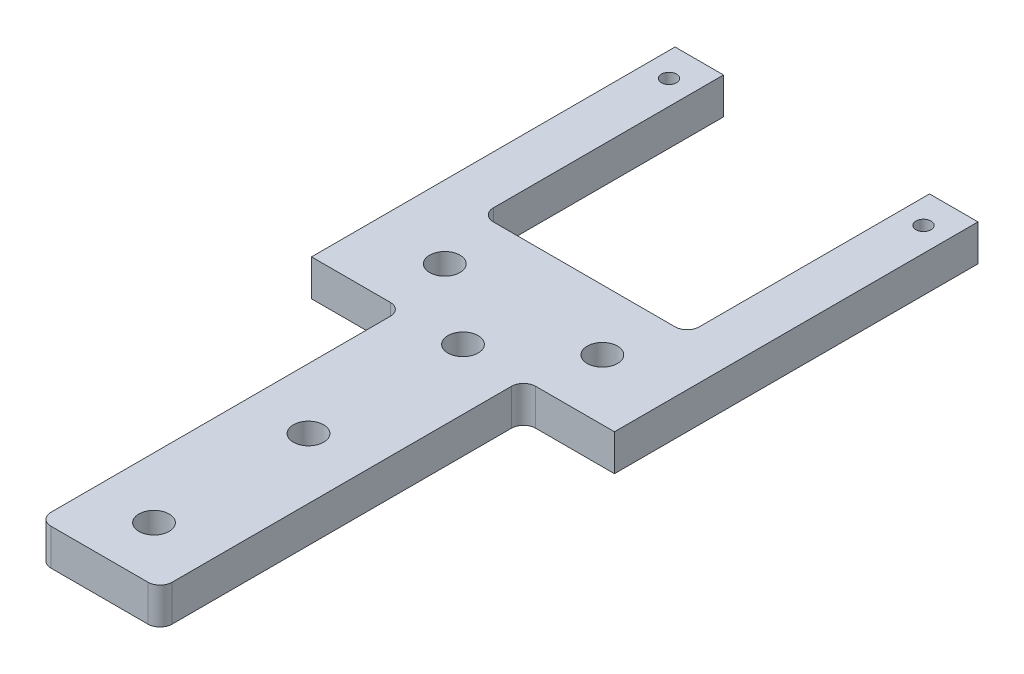
from build123d import *

# Parameters (mm, degrees)
SKETCH1_R           = 1.25
SKETCH1_R_2         = 0.625
BOSS_EXTRUDE1_DEPTH = 1.5
FILLET1_R           = 1


with BuildPart() as part:
    # Sketch1 → Boss-Extrude1 (new body, symmetric)
    with BuildSketch(Plane(origin=(0, 0, 0), x_dir=(1, 0, 0), z_dir=(0, 1, 0))):
        Polygon((-5, 0), (-5, -30), (5, -30), (5, 0), (12.5, 0), (12.5, 30), (8.5, 30), (8.5, 10), (-8.5, 10), (-8.5, 30), (-12.5, 30), (-12.5, 0), align=None)
        Circle(SKETCH1_R, mode=Mode.SUBTRACT)
        with Locations((0, -25.5)):
            Circle(SKETCH1_R, mode=Mode.SUBTRACT)
        with Locations((0, -12.75)):
            Circle(SKETCH1_R, mode=Mode.SUBTRACT)
        with Locations((-6.5, 5)):
            Circle(SKETCH1_R, mode=Mode.SUBTRACT)
        with Locations((6.5, 5)):
            Circle(SKETCH1_R, mode=Mode.SUBTRACT)
        with Locations((-10.5, 27.5)):
            Circle(SKETCH1_R_2, mode=Mode.SUBTRACT)
        with Locations((10.5, 27.5)):
            Circle(SKETCH1_R_2, mode=Mode.SUBTRACT)
    extrude(amount=BOSS_EXTRUDE1_DEPTH, both=True)

    # Fillet1
    fillet1_edges = [part.edges().sort_by_distance(p)[0] for p in [
        (8.5, 0, -10),
        (5, 0, 0),
        (5, 0, 30),
        (-5, 0, 30),
        (-5, 0, 0),
        (-8.5, 0, -10),
    ]]
    fillet(fillet1_edges, radius=FILLET1_R)


solid = part.part
